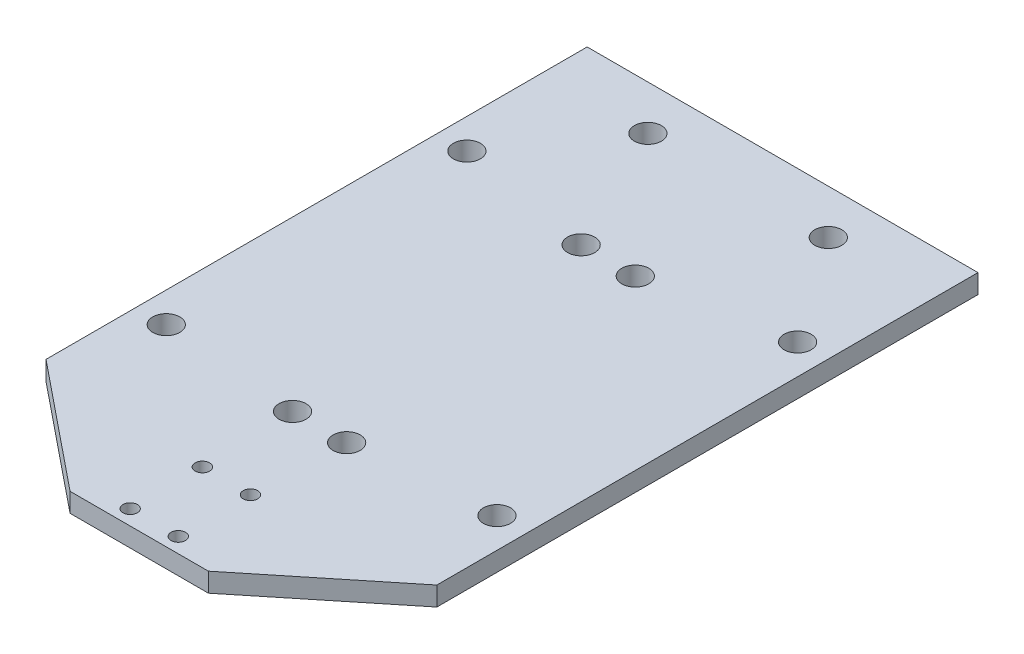
from build123d import *

# Parameters (mm, degrees)
SKETCH1_W            = 65
SKETCH1_H            = 90
SKETCH1_W_2          = 23
SKETCH1_H_2          = 17
BOSS_EXTRUDE1_DEPTH  = 1.5875
M2_CLEARANCE_HOLE1_D = 2.4
M4_CLEARANCE_HOLE1_D = 4.5
M4_CLEARANCE_HOLE2_D = 4.5
M4_CLEARANCE_HOLE3_D = 4.5


with BuildPart() as part:
    # Sketch1 → Boss-Extrude1 (new body, symmetric)
    with BuildSketch(Plane(origin=(0, 0, 0), x_dir=(1, 0, 0), z_dir=(0, 1, 0))):
        Polygon((-32.5, -45), (-11.5, -62), (-11.5, -45), align=None)
        Polygon((11.5, -45), (11.5, -62), (32.5, -45), align=None)
        Rectangle(SKETCH1_W, SKETCH1_H)
        with Locations((0, -53.5)):
            Rectangle(SKETCH1_W_2, SKETCH1_H_2)
    extrude(amount=BOSS_EXTRUDE1_DEPTH, both=True)

    # M2 Clearance Hole1 (through all)
    with Locations(Plane(origin=(0, 1.5875, 0), x_dir=(1, 0, 0), z_dir=(0, 1, 0))):
        with Locations((-4, -59.5), (4, -59.5), (4, -47.5), (-4, -47.5)):
            Hole(M2_CLEARANCE_HOLE1_D / 2)

    # M4 Clearance Hole1 (through all)
    with Locations(Plane(origin=(0, 1.5875, 0), x_dir=(1, 0, 0), z_dir=(0, 1, 0))):
        with Locations((-27.5, 20), (27.5, 20), (27.5, -30), (-27.5, -30)):
            Hole(M4_CLEARANCE_HOLE1_D / 2)

    # M4 Clearance Hole2 (through all)
    with Locations(Plane(origin=(0, 1.5875, 0), x_dir=(1, 0, 0), z_dir=(0, 1, 0))):
        with Locations((-4.5, -32), (4.5, -32), (4.5, 16), (-4.5, 16)):
            Hole(M4_CLEARANCE_HOLE2_D / 2)

    # M4 Clearance Hole3 (through all)
    with Locations(Plane(origin=(0, 1.5875, 0), x_dir=(1, 0, 0), z_dir=(0, 1, 0))):
        with Locations((15, 37.6), (-15, 37.6)):
            Hole(M4_CLEARANCE_HOLE3_D / 2)


solid = part.part
